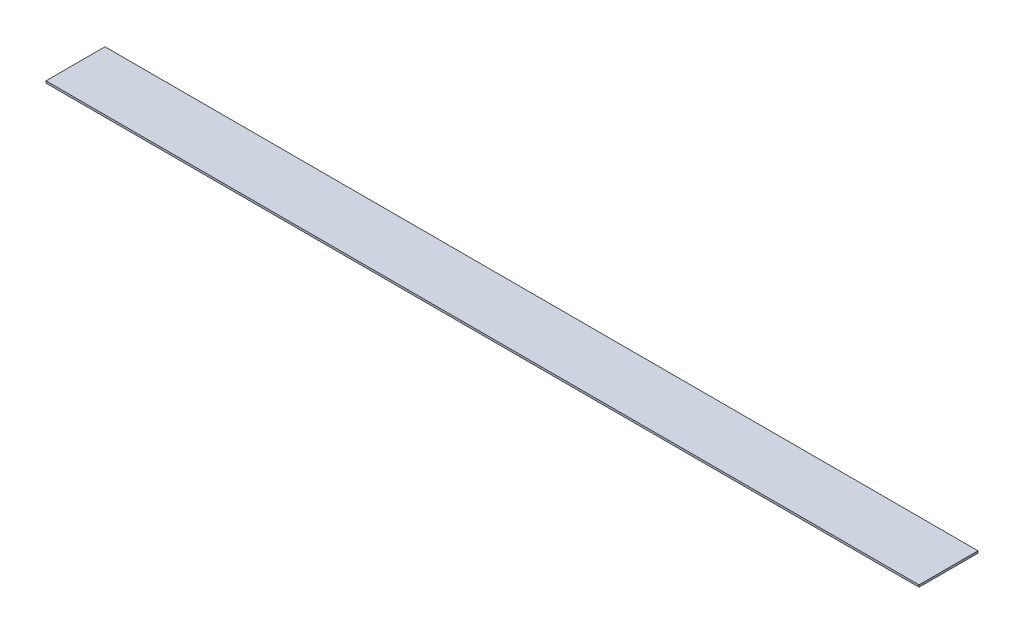
from build123d import *

# Parameters (mm, degrees)
SKETCH1_R           = 3.8
BOSS_EXTRUDE1_DEPTH = 0.9
SKETCH2_W           = 25.6
SKETCH2_H           = 0.9
CUT_EXTRUDE1_DEPTH  = 101


with BuildPart() as part:
    # Sketch1 → Boss-Extrude1 (new body)
    with BuildSketch(Plane(origin=(0, 0, 0), x_dir=(1, 0, 0), z_dir=(0, 1, 0))):
        with BuildLine():
            Line((-240, 12.8), (-240, -12.8))
            Line((-240, -12.8), (234.7, -12.8))
            ThreePointArc((234.7, -12.8), (238.622610201, -6.926940161), (240, 0))
            ThreePointArc((240, 0), (238.622610201, 6.926940161), (234.7, 12.8))
            Line((234.7, 12.8), (-240, 12.8))
        make_face()
        with Locations((230.9, 0)):
            Circle(SKETCH1_R, mode=Mode.SUBTRACT)
    extrude(amount=BOSS_EXTRUDE1_DEPTH)

    # Sketch2 → Cut-Extrude1 (cut)
    with BuildSketch(Plane(origin=(240, 0, 0), x_dir=(0, 0, -1), z_dir=(1, 0, 0))):
        with Locations((0, 0.45)):
            Rectangle(SKETCH2_W, SKETCH2_H)
    extrude(amount=-CUT_EXTRUDE1_DEPTH, mode=Mode.SUBTRACT)


solid = part.part
